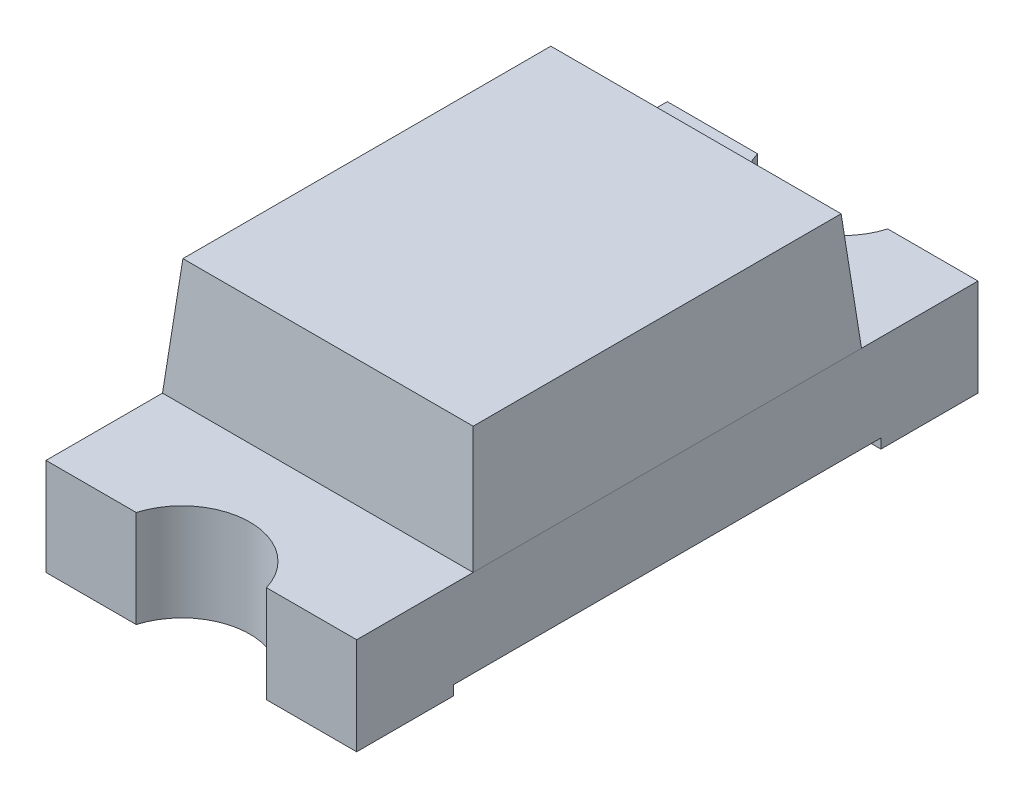
from build123d import *

# Parameters (mm, degrees)
EXTRUDE1_DEPTH      = 0.8
EXTRUDE1_DEPTH_BACK = 0.8
SKETCH2_R           = 0.35
CUT_EXTRUDE1_DEPTH  = 2.857417562
CUT_EXTRUDE2_DEPTH  = 0.005
SKETCH4_W           = 0.39
SKETCH4_H           = 0.39
EXTRUDE2_DEPTH      = 0.25
SKETCH5_W           = 1.6
SKETCH5_H           = 2
EXTRUDE3_DEPTH      = 0.6
EXTRUDE3_TAPER      = 5


with BuildPart() as part:
    # Sketch1 → Extrude1 (new, two sides: drawn at the far end of the back side and taken through both)
    with BuildSketch(Plane(origin=(0, 0, 0), x_dir=(0, 0, -1), z_dir=(1, 0, 0)).offset(-EXTRUDE1_DEPTH_BACK)):
        Polygon((1.1, 0), (1.6, 0), (1.6, 0.5), (-1.6, 0.5), (-1.6, 0), (-1.1, 0), (-1.1, 0.05), (1.1, 0.05), align=None)
    extrude(amount=EXTRUDE1_DEPTH + EXTRUDE1_DEPTH_BACK)

    # Sketch2 → Cut-Extrude1 (cut, through all)
    with BuildSketch(Plane(origin=(0, 0, 0), x_dir=(1, 0, 0), z_dir=(0, 1, 0))):
        with Locations((0, 1.7)):
            Circle(SKETCH2_R)
        with Locations((0, -1.7)):
            Circle(SKETCH2_R)
    extrude(amount=CUT_EXTRUDE1_DEPTH, mode=Mode.SUBTRACT)

    # Sketch3 → Cut-Extrude2 (cut)
    with BuildSketch(Plane(origin=(0, 0.5, 0), x_dir=(-1, 0, 0), z_dir=(0, 1, 0))):
        Polygon((0.27741461, -1), (0.45741461, -1), (0.45741461, -0.450698672), (-0.276447509, -0.450698672), (-0.276447509, -0.630698672), (0.27741461, -0.630698672), align=None)
        Polygon((-0.225, -0.225), (0.225, -0.225), (0.225, 0.675), (-0.327379025, 0.675), (-0.327379025, 1), (-0.477379025, 1), (-0.477379025, 0.525), (0.075, 0.525), (0.075, 0.225), (-0.225, 0.225), align=None)
    extrude(amount=-CUT_EXTRUDE2_DEPTH, mode=Mode.SUBTRACT)

    # Sketch4 → Extrude2 (add)
    with BuildSketch(Plane(origin=(0, 0.495, 0), x_dir=(-1, 0, 0), z_dir=(0, 1, 0))):
        Rectangle(SKETCH4_W, SKETCH4_H)
    extrude(amount=EXTRUDE2_DEPTH)


with BuildPart() as body_2:
    # Sketch5 → Extrude3 (new body)
    with BuildSketch(Plane(origin=(0, 0.5, 0), x_dir=(-1, 0, 0), z_dir=(0, 1, 0))):
        Rectangle(SKETCH5_W, SKETCH5_H)
    extrude(amount=EXTRUDE3_DEPTH, taper=EXTRUDE3_TAPER)


solid = Compound([part.part, body_2.part])
